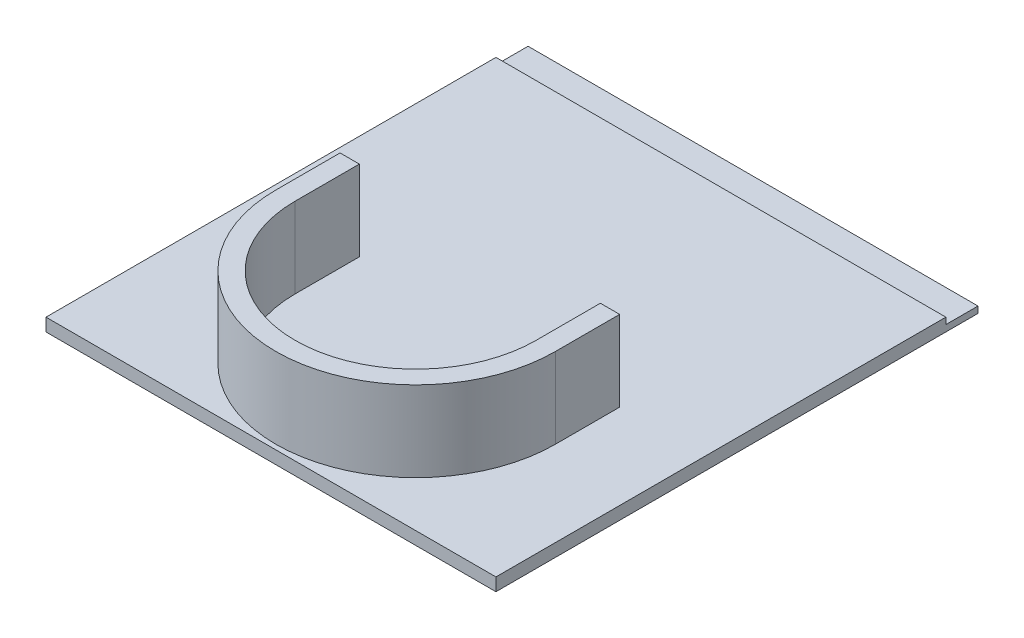
from build123d import *

# Parameters (mm, degrees)
SKETCH2_W               = 140
SKETCH2_H               = 420
BOSS_EXTRUDE1_DEPTH     = 4
BOSS_EXTRUDE2_DEPTH     = 25
SKETCH4_W               = 10.25
SKETCH4_H               = 80.25
CUT_EXTRUDE1_DEPTH      = 25.4
SKETCH7_W               = 130
SKETCH7_H               = 10
CUT_EXTRUDE2_DEPTH      = 2.45
SKETCH8_W               = 140
SKETCH8_H               = 140
SKETCH8_W_2             = 10.25
SKETCH8_H_2             = 80.25
CUT_EXTRUDE3_DEPTH      = 1
CUT_EXTRUDE3_DEPTH_BACK = 30
SKETCH9_W               = 140
SKETCH9_H               = 10
BOSS_EXTRUDE3_DEPTH     = 2


with BuildPart() as part:
    # Sketch2 → Boss-Extrude1 (new body)
    with BuildSketch(Plane(origin=(0, 0, 0), x_dir=(1, 0, 0), z_dir=(0, 1, 0))):
        Rectangle(SKETCH2_W, SKETCH2_H)
    extrude(amount=BOSS_EXTRUDE1_DEPTH)

    # Sketch3 → Boss-Extrude2 (add)
    with BuildSketch(Plane(origin=(0, 4, 0), x_dir=(1, 0, 0), z_dir=(0, 1, 0))):
        with BuildLine():
            Line((-37.5, -165), (-37.5, -145))
            Line((-37.5, -145), (-43.5, -145))
            Line((-43.5, -145), (-43.5, -165))
            ThreePointArc((-43.5, -165), (0, -208.5), (43.5, -165))
            Line((43.5, -165), (43.5, -145))
            Line((43.5, -145), (37.5, -145))
            Line((37.5, -145), (37.5, -165))
            ThreePointArc((37.5, -165), (0, -202.5), (-37.5, -165))
        make_face()
    extrude(amount=BOSS_EXTRUDE2_DEPTH)

    # Sketch4 → Cut-Extrude1 (cut)
    with BuildSketch(Plane(origin=(0, 4, 0), x_dir=(1, 0, 0), z_dir=(0, 1, 0))):
        with Locations((-59.875, 139.875)):
            Rectangle(SKETCH4_W, SKETCH4_H)
        with Locations((59.875, 139.875)):
            Rectangle(SKETCH4_W, SKETCH4_H)
    extrude(amount=-CUT_EXTRUDE1_DEPTH, mode=Mode.SUBTRACT)

    # Sketch7 → Cut-Extrude2 (cut)
    with BuildSketch(Plane(origin=(0, 4, 0), x_dir=(1, 0, 0), z_dir=(0, 1, 0))):
        with Locations((0, 200)):
            Rectangle(SKETCH7_W, SKETCH7_H)
    extrude(amount=-CUT_EXTRUDE2_DEPTH, mode=Mode.SUBTRACT)

    # Sketch8 → Cut-Extrude3 (cut, two sides)
    with BuildSketch(Plane.XZ) as cut_extrude3_sk:
        with Locations((0, -140)):
            Rectangle(SKETCH8_W, SKETCH8_H)
        with Locations((-59.875, -139.875)):
            Rectangle(SKETCH8_W_2, SKETCH8_H_2, mode=Mode.SUBTRACT)
        with Locations((59.875, -139.875)):
            Rectangle(SKETCH8_W_2, SKETCH8_H_2, mode=Mode.SUBTRACT)
        Rectangle(SKETCH8_W, SKETCH8_H)
    extrude(amount=CUT_EXTRUDE3_DEPTH, mode=Mode.SUBTRACT)
    extrude(cut_extrude3_sk.sketch, amount=-CUT_EXTRUDE3_DEPTH_BACK, mode=Mode.SUBTRACT)

    # Sketch9 → Boss-Extrude3 (add)
    with BuildSketch(Plane.XZ):
        with Locations((0, 65)):
            Rectangle(SKETCH9_W, SKETCH9_H)
    extrude(amount=-BOSS_EXTRUDE3_DEPTH)


solid = part.part
